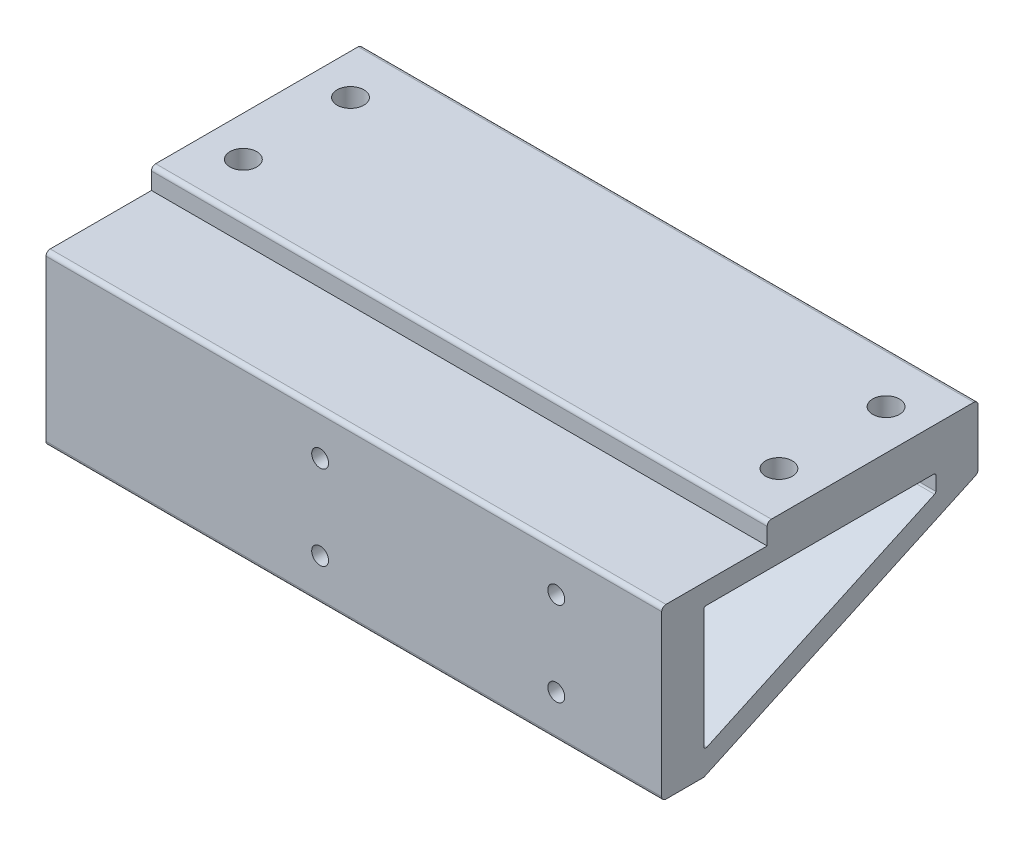
from build123d import *

# Parameters (mm, degrees)
SKETCH1_W           = 146
SKETCH1_H           = 50
BOSS_EXTRUDE1_DEPTH = 5
BOSS_EXTRUDE2_DEPTH = 146
SKETCH4_R           = 3.175
CUT_EXTRUDE1_DEPTH  = 25
SKETCH11_R          = 2
CUT_EXTRUDE3_DEPTH  = 10
SKETCH13_W          = 106
SKETCH13_H          = 65
CUT_EXTRUDE5_DEPTH  = 35
FILLET1_R           = 0.5
FILLET2_R           = 1


with BuildPart() as part:
    # Sketch1 → Boss-Extrude1 (new body)
    with BuildSketch(Plane(origin=(0, 0, 0), x_dir=(1, 0, 0), z_dir=(0, 1, 0))):
        with Locations((73, 25)):
            Rectangle(SKETCH1_W, SKETCH1_H)
    extrude(amount=BOSS_EXTRUDE1_DEPTH)

    # Sketch10 → Boss-Extrude2 (add)
    with BuildSketch(Plane(origin=(146, 0, 0), x_dir=(0, 0, -1), z_dir=(1, 0, 0))):
        Polygon((-25, 0), (-25, -40), (-15, -40), (50, -10), (50, 0), align=None)
        Polygon((-15, -34.493146), (-15, -5), (40, -5), (40, -9.10853), align=None, mode=Mode.SUBTRACT)
    extrude(amount=-BOSS_EXTRUDE2_DEPTH)

    # Sketch4 → Cut-Extrude1 (cut)
    with BuildSketch(Plane(origin=(0, 5, 0), x_dir=(1, 0, 0), z_dir=(0, 1, 0))):
        with Locations((9.5, 37.7)):
            Circle(SKETCH4_R)
        with Locations((9.5, 12.3)):
            Circle(SKETCH4_R)
        with Locations((136.5, 12.3)):
            Circle(SKETCH4_R)
        with Locations((136.5, 37.7)):
            Circle(SKETCH4_R)
    extrude(amount=-CUT_EXTRUDE1_DEPTH, mode=Mode.SUBTRACT)

    # Sketch11 → Cut-Extrude3 (cut)
    with BuildSketch(Plane.XY.offset(25)):
        with Locations((121, -30)):
            Circle(SKETCH11_R)
        with Locations((65, -30)):
            Circle(SKETCH11_R)
        with Locations((65, -10)):
            Circle(SKETCH11_R)
        with Locations((121, -10)):
            Circle(SKETCH11_R)
    extrude(amount=-CUT_EXTRUDE3_DEPTH, mode=Mode.SUBTRACT)

    # Sketch13 → Cut-Extrude5 (cut)
    with BuildSketch(Plane.XZ.offset(40)):
        with Locations((73, -17.5)):
            Rectangle(SKETCH13_W, SKETCH13_H)
    extrude(amount=-CUT_EXTRUDE5_DEPTH, mode=Mode.SUBTRACT)

    # Fillet1
    fillet1_edges = [part.edges().sort_by_distance(p)[0] for p in [
        (73, -5, 15),
        (10, -34.493146, 15),
        (136, -34.493146, 15),
        (15.844375, -9.10853, -40),
        (15.844375, -5, -40),
        (130.155625, -9.10853, -40),
        (130.155625, -5, -40),
        (142.344375, -5, -40),
        (142.344375, -9.10853, -40),
        (3.655625, -5, -40),
        (3.655625, -9.10853, -40),
    ]]
    fillet(fillet1_edges, radius=FILLET1_R)

    # Fillet2
    fillet2_edges = [part.edges().sort_by_distance(p)[0] for p in [
        (73, 0, 25),
        (73, 5, -50),
        (10, -10, -50),
        (73, -40, 25),
        (73, 5, 0),
        (136, -10, -50),
    ]]
    fillet(fillet2_edges, radius=FILLET2_R)


solid = part.part
